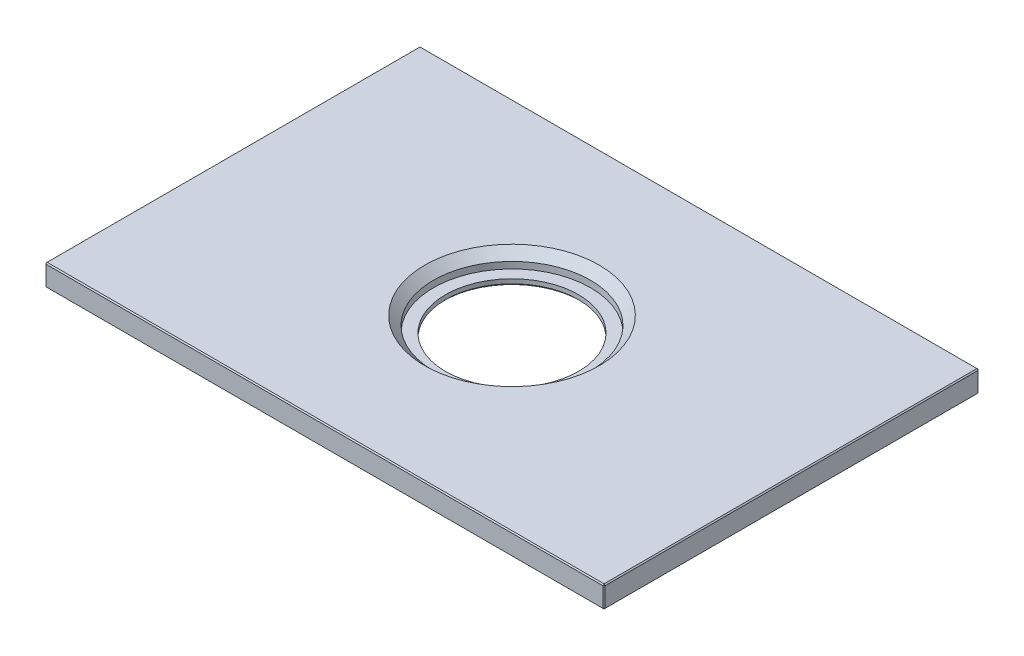
from build123d import *

# Parameters (mm, degrees)
SKETCH1_W      = 128.2
SKETCH1_H      = 86
EXTRUDE1_DEPTH = 5
SKETCH4_R      = 18
EXTRUDE4_DEPTH = 3.5
SKETCH6_R      = 15.25
EXTRUDE6_DEPTH = 2.5
CHAMFER5_SIZE  = 0.5
CHAMFER6_SIZE  = 2
CHAMFER7_SIZE  = 0.25


with BuildPart() as part:
    # Sketch1 → Extrude1 (new body)
    with BuildSketch(Plane(origin=(0, 0, 0), x_dir=(1, 0, 0), z_dir=(0, 1, 0))):
        Rectangle(SKETCH1_W, SKETCH1_H)
    extrude(amount=EXTRUDE1_DEPTH)

    # Sketch4 → Extrude4 (cut)
    with BuildSketch(Plane(origin=(0, 5, 0), x_dir=(-1, 0, 0), z_dir=(0, 1, 0))):
        Circle(SKETCH4_R)
    extrude(amount=-EXTRUDE4_DEPTH, mode=Mode.SUBTRACT)

    # Sketch6 → Extrude6 (cut, through all)
    with BuildSketch(Plane(origin=(0, 1.5, 0), x_dir=(1, 0, 0), z_dir=(0, 1, 0))):
        Circle(SKETCH6_R)
    extrude(amount=-EXTRUDE6_DEPTH, mode=Mode.SUBTRACT)

    # Chamfer5
    chamfer5_edges = [part.edges().sort_by_distance(p)[0] for p in [
        (-15.25, 0, 0),
    ]]
    chamfer(chamfer5_edges, length=CHAMFER5_SIZE)

    # Chamfer6
    chamfer6_edges = [part.edges().sort_by_distance(p)[0] for p in [
        (18, 5, 0),
    ]]
    chamfer(chamfer6_edges, length=CHAMFER6_SIZE)

    # Chamfer7
    chamfer7_edges = [part.edges().sort_by_distance(p)[0] for p in [
        (-64.1, 5, 0),
        (0, 5, 43),
        (64.1, 5, 0),
        (0, 0, 43),
        (-64.1, 0, 0),
        (0, 0, -43),
        (64.1, 0, 0),
        (0, 5, -43),
        (64.1, 2.5, 43),
        (-64.1, 2.5, 43),
        (-64.1, 2.5, -43),
        (64.1, 2.5, -43),
    ]]
    chamfer(chamfer7_edges, length=CHAMFER7_SIZE)


solid = part.part
